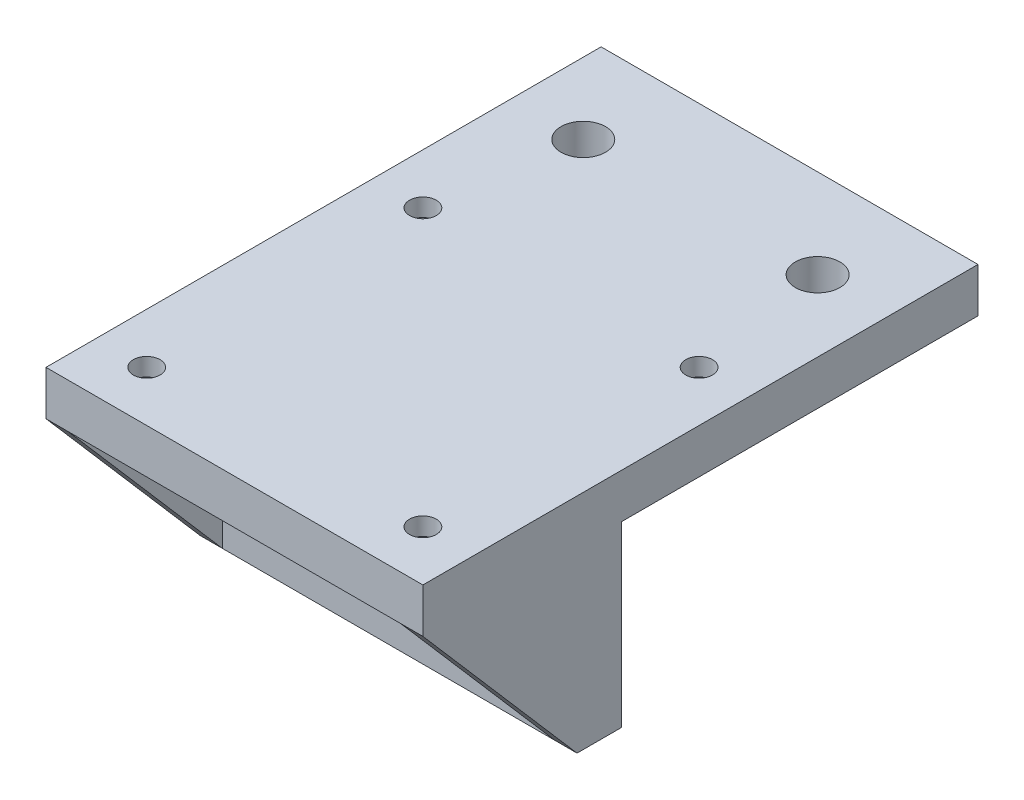
from build123d import *

# Parameters (mm, degrees)
SKETCH1_R           = 1.5
BOSS_EXTRUDE1_DEPTH = 5
SKETCH2_R           = 2.75
CUT_EXTRUDE1_DEPTH  = 3
SKETCH3_W           = 42.3
SKETCH3_H           = 5
BOSS_EXTRUDE2_DEPTH = 20
SKETCH7_R           = 2.5
CUT_EXTRUDE4_DEPTH  = 55.03373946
SKETCH8_R           = 2.5
CUT_EXTRUDE5_DEPTH  = 53.589400073
RIB1_REACH          = 64.311
SKETCH9_WALL_W      = 153.06531809
SKETCH9_WALL_H      = 2.5


with BuildPart() as part:
    # Sketch1 → Boss-Extrude1 (new body)
    with BuildSketch(Plane(origin=(0, 0, 0), x_dir=(1, 0, 0), z_dir=(0, 1, 0))):
        Polygon((-21.15, -21.15), (21.15, -21.15), (21.15, 21.15), (21.15, 41.15), (-21.15, 41.15), (-21.15, 21.15), align=None)
        with Locations(Location((-15.5, 15.5, 0), (0, 0, 270))):
            Circle(SKETCH1_R, mode=Mode.SUBTRACT)
        with Locations(Location((15.5, 15.5, 0), (0, 0, 270))):
            Circle(SKETCH1_R, mode=Mode.SUBTRACT)
        with Locations(Location((-15.5, -15.5, 0), (0, 0, 270))):
            Circle(SKETCH1_R, mode=Mode.SUBTRACT)
        with Locations(Location((15.5, -15.5, 0), (0, 0, 270))):
            Circle(SKETCH1_R, mode=Mode.SUBTRACT)
    extrude(amount=BOSS_EXTRUDE1_DEPTH)

    # Sketch2 → Cut-Extrude1 (cut)
    with BuildSketch(Plane.XZ):
        with Locations(Location((-15.5, 15.5, 0), (0, 0, 270))):
            Circle(SKETCH2_R)
        with Locations(Location((-15.5, -15.5, 0), (0, 0, 270))):
            Circle(SKETCH2_R)
        with Locations(Location((15.5, 15.5, 0), (0, 0, 270))):
            Circle(SKETCH2_R)
        with Locations(Location((15.5, -15.5, 0), (0, 0, 270))):
            Circle(SKETCH2_R)
    extrude(amount=-CUT_EXTRUDE1_DEPTH, mode=Mode.SUBTRACT)

    # Sketch3 → Boss-Extrude2 (add)
    with BuildSketch(Plane.XZ):
        with Locations((0, 1.35)):
            Rectangle(SKETCH3_W, SKETCH3_H)
    extrude(amount=BOSS_EXTRUDE2_DEPTH)

    # Sketch7 → Cut-Extrude4 (cut, through all)
    with BuildSketch(Plane(origin=(0, 1.15, 3.85), x_dir=(1, 0, 0), z_dir=(0, 0, -1))):
        with Locations((-13.15, 11.15)):
            Circle(SKETCH7_R)
        with Locations((13.15, 11.15)):
            Circle(SKETCH7_R)
    extrude(amount=CUT_EXTRUDE4_DEPTH, mode=Mode.SUBTRACT)

    # Sketch8 → Cut-Extrude5 (cut, through all)
    with BuildSketch(Plane(origin=(0, 5, 0), x_dir=(1, 0, 0), z_dir=(0, 1, 0))):
        with Locations(Location((-13.15, 31.15, 0), (0, 0, 270))):
            Circle(SKETCH8_R)
        with Locations(Location((13.15, 31.15, 0), (0, 0, 270))):
            Circle(SKETCH8_R)
    extrude(amount=-CUT_EXTRUDE5_DEPTH, mode=Mode.SUBTRACT)

    # Sketch9 wall → Rib1 (add, up to next)
    with BuildSketch(Plane(origin=(-21.15, -10, 12.5), x_dir=(0, 0.756312601861, 0.65421040061), z_dir=(0, 0.65421040061, -0.756312601861)), mode=Mode.PRIVATE) as rib1_sk1:
        with Locations((0, 1.25)):
            Rectangle(SKETCH9_WALL_W, SKETCH9_WALL_H)
    rib1_tool1 = extrude(rib1_sk1.sketch, amount=RIB1_REACH, mode=Mode.PRIVATE) - part.part
    rib1 = rib1_tool1.solids().sort_by_distance((-21.15, -10, 12.5))[0]
    add(rib1)

    # Mirror1: Rib1 across plane
    add(rib1.mirror(Plane.ZY))


solid = part.part
